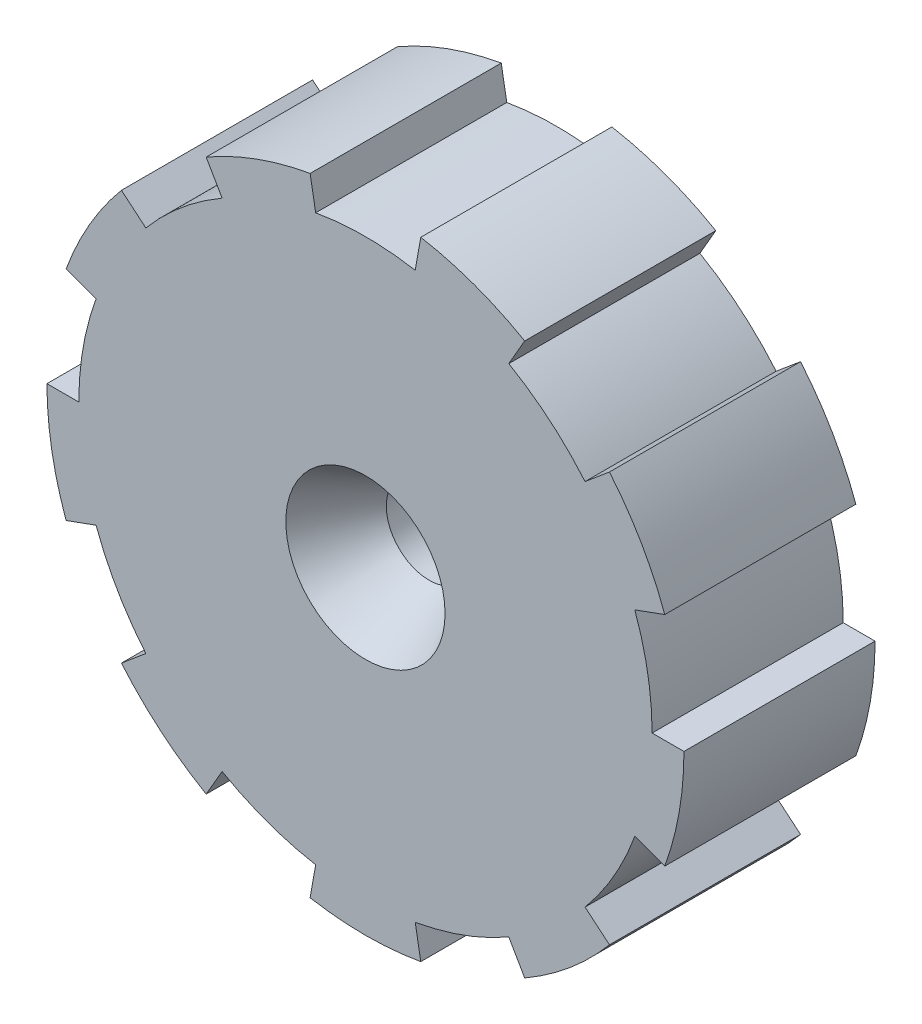
from build123d import *

# Parameters (mm, degrees)
BOSS_EXTRUDE1_DEPTH = 30
SKETCH_2_R          = 12.5
CUT_EXTRUDE1_DEPTH  = 10
CUT_EXTRUDE1_TAPER  = 30
SKETCH3_OUTSIDE_W   = 142.356
SKETCH3_OUTSIDE_H   = 141.596
SKETCH3_OUTSIDE_R   = 12.5
CUT_EXTRUDE4_DEPTH  = 10
CUT_EXTRUDE4_TAPER  = 30
SKETCH8_R           = 6.726497308
CUT_EXTRUDE5_DEPTH  = 60


with BuildPart() as part:
    # Sketch1 → Boss-Extrude1 (new body)
    with BuildSketch(Plane.XY):
        with BuildLine():
            Line((-7.814167995, 44.316348886), (-8.682408883, 49.240387651))
            ThreePointArc((-8.682408883, 49.240387651), (-17.101007166, 46.984631039), (-25, 43.301270189))
            Line((-25, 43.301270189), (-22.5, 38.97114317))
            ThreePointArc((-22.5, 38.97114317), (-28.925442436, 34.47199994), (-34.47199994, 28.925442436))
            Line((-34.47199994, 28.925442436), (-38.302222156, 32.139380484))
            ThreePointArc((-38.302222156, 32.139380484), (-43.301270189, 25), (-46.984631039, 17.101007166))
            Line((-46.984631039, 17.101007166), (-42.286167935, 15.39090645))
            ThreePointArc((-42.286167935, 15.39090645), (-44.316348886, 7.814167995), (-45, 0))
            Line((-45, 0), (-50, 0))
            ThreePointArc((-50, 0), (-49.240387651, -8.682408883), (-46.984631039, -17.101007166))
            Line((-46.984631039, -17.101007166), (-42.286167935, -15.39090645))
            ThreePointArc((-42.286167935, -15.39090645), (-38.97114317, -22.5), (-34.47199994, -28.925442436))
            Line((-34.47199994, -28.925442436), (-38.302222156, -32.139380484))
            ThreePointArc((-38.302222156, -32.139380484), (-32.139380484, -38.302222156), (-25, -43.301270189))
            Line((-25, -43.301270189), (-22.5, -38.97114317))
            ThreePointArc((-22.5, -38.97114317), (-15.39090645, -42.286167935), (-7.814167995, -44.316348886))
            Line((-7.814167995, -44.316348886), (-8.682408883, -49.240387651))
            ThreePointArc((-8.682408883, -49.240387651), (0, -50), (8.682408883, -49.240387651))
            Line((8.682408883, -49.240387651), (7.814167995, -44.316348886))
            ThreePointArc((7.814167995, -44.316348886), (15.39090645, -42.286167935), (22.5, -38.97114317))
            Line((22.5, -38.97114317), (25, -43.301270189))
            ThreePointArc((25, -43.301270189), (32.139380484, -38.302222156), (38.302222156, -32.139380484))
            Line((38.302222156, -32.139380484), (34.47199994, -28.925442436))
            ThreePointArc((34.47199994, -28.925442436), (38.97114317, -22.5), (42.286167935, -15.39090645))
            Line((42.286167935, -15.39090645), (46.984631039, -17.101007166))
            ThreePointArc((46.984631039, -17.101007166), (49.240387651, -8.682408883), (50, 0))
            Line((50, 0), (45, 0))
            ThreePointArc((45, 0), (44.316348886, 7.814167995), (42.286167935, 15.39090645))
            Line((42.286167935, 15.39090645), (46.984631039, 17.101007166))
            ThreePointArc((46.984631039, 17.101007166), (43.301270189, 25), (38.302222156, 32.139380484))
            Line((38.302222156, 32.139380484), (34.47199994, 28.925442436))
            ThreePointArc((34.47199994, 28.925442436), (28.925442436, 34.47199994), (22.5, 38.97114317))
            Line((22.5, 38.97114317), (25, 43.301270189))
            ThreePointArc((25, 43.301270189), (17.101007166, 46.984631039), (8.682408883, 49.240387651))
            Line((8.682408883, 49.240387651), (7.814167995, 44.316348886))
            ThreePointArc((7.814167995, 44.316348886), (0, 45), (-7.814167995, 44.316348886))
        make_face()
    extrude(amount=BOSS_EXTRUDE1_DEPTH)

    # Sketch 2 → Cut-Extrude1 (cut)
    with BuildSketch(Plane.XY.offset(30)):
        Circle(SKETCH_2_R)
    extrude(amount=-CUT_EXTRUDE1_DEPTH, taper=CUT_EXTRUDE1_TAPER, mode=Mode.SUBTRACT)

    # Sketch3 outside → Cut-Extrude4 (cut)
    with BuildSketch(Plane(origin=(0, 0, 0), x_dir=(-1, 0, 0), z_dir=(0, 0, -1))):
        with Locations((0, -0.38)):
            Rectangle(SKETCH3_OUTSIDE_W, SKETCH3_OUTSIDE_H)
        with BuildLine():
            Line((-7.814167995, 44.316348886), (-8.682408883, 49.240387651))
            ThreePointArc((-8.682408883, 49.240387651), (-17.101007166, 46.984631039), (-25, 43.301270189))
            Line((-25, 43.301270189), (-22.5, 38.97114317))
            ThreePointArc((-22.5, 38.97114317), (-28.925442436, 34.47199994), (-34.47199994, 28.925442436))
            Line((-34.47199994, 28.925442436), (-38.302222156, 32.139380484))
            ThreePointArc((-38.302222156, 32.139380484), (-43.301270189, 25), (-46.984631039, 17.101007166))
            Line((-46.984631039, 17.101007166), (-42.286167935, 15.39090645))
            ThreePointArc((-42.286167935, 15.39090645), (-44.316348886, 7.814167995), (-45, 0))
            Line((-45, 0), (-50, 0))
            ThreePointArc((-50, 0), (-49.240387651, -8.682408883), (-46.984631039, -17.101007166))
            Line((-46.984631039, -17.101007166), (-42.286167935, -15.39090645))
            ThreePointArc((-42.286167935, -15.39090645), (-38.97114317, -22.5), (-34.47199994, -28.925442436))
            Line((-34.47199994, -28.925442436), (-38.302222156, -32.139380484))
            ThreePointArc((-38.302222156, -32.139380484), (-32.139380484, -38.302222156), (-25, -43.301270189))
            Line((-25, -43.301270189), (-22.5, -38.97114317))
            ThreePointArc((-22.5, -38.97114317), (-15.39090645, -42.286167935), (-7.814167995, -44.316348886))
            Line((-7.814167995, -44.316348886), (-8.682408883, -49.240387651))
            ThreePointArc((-8.682408883, -49.240387651), (0, -50), (8.682408883, -49.240387651))
            Line((8.682408883, -49.240387651), (7.814167995, -44.316348886))
            ThreePointArc((7.814167995, -44.316348886), (15.39090645, -42.286167935), (22.5, -38.97114317))
            Line((22.5, -38.97114317), (25, -43.301270189))
            ThreePointArc((25, -43.301270189), (32.139380484, -38.302222156), (38.302222156, -32.139380484))
            Line((38.302222156, -32.139380484), (34.47199994, -28.925442436))
            ThreePointArc((34.47199994, -28.925442436), (38.97114317, -22.5), (42.286167935, -15.39090645))
            Line((42.286167935, -15.39090645), (46.984631039, -17.101007166))
            ThreePointArc((46.984631039, -17.101007166), (49.240387651, -8.682408883), (50, 0))
            Line((50, 0), (45, 0))
            ThreePointArc((45, 0), (44.316348886, 7.814167995), (42.286167935, 15.39090645))
            Line((42.286167935, 15.39090645), (46.984631039, 17.101007166))
            ThreePointArc((46.984631039, 17.101007166), (43.301270189, 25), (38.302222156, 32.139380484))
            Line((38.302222156, 32.139380484), (34.47199994, 28.925442436))
            ThreePointArc((34.47199994, 28.925442436), (28.925442436, 34.47199994), (22.5, 38.97114317))
            Line((22.5, 38.97114317), (25, 43.301270189))
            ThreePointArc((25, 43.301270189), (17.101007166, 46.984631039), (8.682408883, 49.240387651))
            Line((8.682408883, 49.240387651), (7.814167995, 44.316348886))
            ThreePointArc((7.814167995, 44.316348886), (0, 45), (-7.814167995, 44.316348886))
        make_face(mode=Mode.SUBTRACT)
        Circle(SKETCH3_OUTSIDE_R)
    extrude(amount=-CUT_EXTRUDE4_DEPTH, taper=CUT_EXTRUDE4_TAPER, mode=Mode.SUBTRACT)

    # Sketch8 → Cut-Extrude5 (cut)
    with BuildSketch(Plane.XY.offset(20)):
        Circle(SKETCH8_R)
    extrude(amount=-CUT_EXTRUDE5_DEPTH, mode=Mode.SUBTRACT)


solid = part.part
